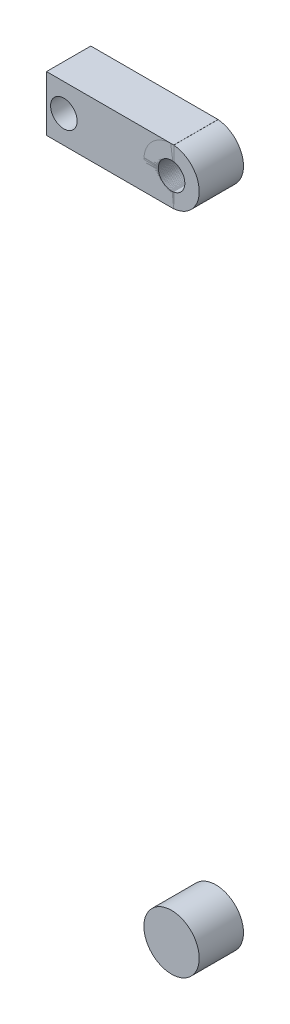
from build123d import *

# Parameters (mm, degrees)
ESBO_O1_R                     = 12.5
RESSALTO_EXTRUS_O6_DEPTH      = 20
RESSALTO_EXTRUS_O6_2_DEPTH    = 20
ESBO_O3_W                     = 20
ESBO_O3_H                     = 25
RESSALTO_EXTRUS_O7_DEPTH      = 12.5
RESSALTO_EXTRUS_O7_DEPTH_BACK = 45
ESBO_O4_R                     = 6
CORTE_EXTRUS_O1_DEPTH         = 45


with BuildPart() as part:
    # Esboço1 → Ressalto-extrusão6 (new body)
    with BuildSketch(Plane.XY):
        with Locations((11.498120919, 4.903388149)):
            Circle(ESBO_O1_R)
    extrude(amount=RESSALTO_EXTRUS_O6_DEPTH)


with BuildPart() as body_2:
    # Esboço1 → Ressalto-extrus_o6 2 (new body)
    with BuildSketch(Plane.XY):
        with Locations((11.498120919, -295.096611851)):
            Circle(ESBO_O1_R)
    extrude(amount=RESSALTO_EXTRUS_O6_2_DEPTH)


with BuildPart() as body_3:
    # Esboço3 → Ressalto-extrusão7 (new body, two sides)
    with BuildSketch(Plane(origin=(0, 0, 0), x_dir=(0, 0, -1), z_dir=(1, 0, 0))) as ressalto_extrus_o7_sk:
        with Locations((-10, 4.903388149)):
            Rectangle(ESBO_O3_W, ESBO_O3_H)
    extrude(amount=RESSALTO_EXTRUS_O7_DEPTH)
    extrude(ressalto_extrus_o7_sk.sketch, amount=-RESSALTO_EXTRUS_O7_DEPTH_BACK)


with BuildPart() as corte_extrus_o1_tool:
    # Esboço4 → Corte-extrusão1 (new body)
    with BuildSketch(Plane.XY.offset(20)):
        with Locations((11.498120919, 4.903388149)):
            Circle(ESBO_O4_R)
        with Locations((-37.165592143, 4.903388149)):
            Circle(ESBO_O4_R)
    extrude(amount=-CORTE_EXTRUS_O1_DEPTH)


with BuildPart() as part_1:
    add(part.part)

    # Corte-extrusão1: cut by corte_extrus_o1_tool
    add(corte_extrus_o1_tool.part, mode=Mode.SUBTRACT)


with BuildPart() as body_3_1:
    add(body_3.part)

    # Corte-extrusão1: cut by corte_extrus_o1_tool
    add(corte_extrus_o1_tool.part, mode=Mode.SUBTRACT)


solid = Compound([body_2.part, part_1.part, body_3_1.part])
